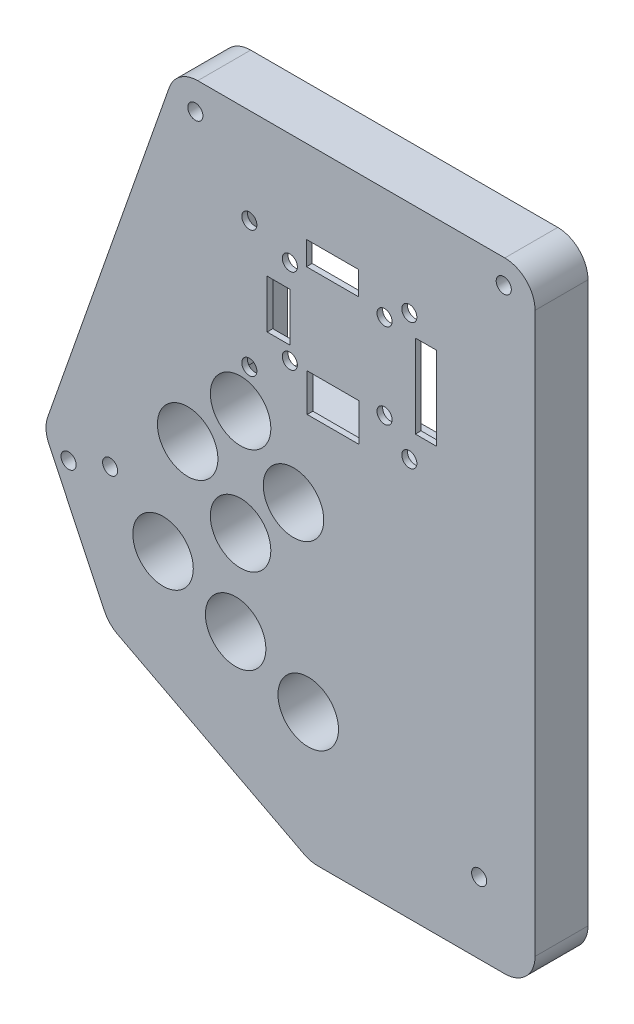
from build123d import *

# Parameters (mm, degrees)
BOSS_EXTRUDE1_DEPTH      = 8.89
SKETCH9_R                = 1.267511842
SKETCH9_W                = 3.81
SKETCH9_H                = 8.128
SKETCH9_W_2              = 3.556
SKETCH9_H_2              = 13.97
SKETCH9_W_3              = 8.73125
SKETCH9_H_3              = 3.96875
CUT_EXTRUDE6_DEPTH       = 1
CUT_EXTRUDE6_DEPTH_BACK  = 9.89
SKETCH4_W                = 34.29
SKETCH4_H                = 30.48
CUT_EXTRUDE7_DEPTH       = 7.9375
CUT_EXTRUDE7_DEPTH_BACK  = 1
SKETCH3_R                = 5.08
CUT_EXTRUDE8_DEPTH       = 1
CUT_EXTRUDE8_DEPTH_BACK  = 9.89
SKETCH12_R               = 1.27
CUT_EXTRUDE9_DEPTH       = 1
CUT_EXTRUDE9_DEPTH_BACK  = 9.89
SKETCH15_R               = 1.27
CUT_EXTRUDE10_DEPTH      = 1
CUT_EXTRUDE10_DEPTH_BACK = 9.89


with BuildPart() as part:
    # Sketch1 → Boss-Extrude1 (new body)
    with BuildSketch(Plane.XY):
        with BuildLine():
            Line((-3.314058103, 6.35), (48.26, 6.35))
            ThreePointArc((48.26, 6.35), (51.852102448, 4.862102448), (53.34, 1.27))
            Line((53.34, 1.27), (53.34, -92.71))
            ThreePointArc((53.34, -92.71), (51.852102448, -96.302102448), (48.26, -97.79))
            Line((48.26, -97.79), (16.846989059, -97.79))
            ThreePointArc((16.846989059, -97.79), (15.638688158, -97.644208035), (14.499741809, -97.215200367))
            Line((14.499741809, -97.215200367), (-16.7505185, -80.933552139))
            ThreePointArc((-16.7505185, -80.933552139), (-18.059258376, -79.955412607), (-18.989802686, -78.61241436))
            Line((-18.989802686, -78.61241436), (-28.309569459, -59.040904135))
            ThreePointArc((-28.309569459, -59.040904135), (-28.795802898, -57.127870198), (-28.51617555, -55.173917704))
            Line((-28.51617555, -55.173917704), (-8.107195629, 2.952923842))
            ThreePointArc((-8.107195629, 2.952923842), (-6.251501454, 5.414614163), (-3.314058103, 6.35))
        make_face()
    extrude(amount=BOSS_EXTRUDE1_DEPTH)

    # Sketch9 → Cut-Extrude6 (cut, two sides)
    with BuildSketch(Plane(origin=(0, 0, 0), x_dir=(-1, 0, 0), z_dir=(0, 0, -1))) as cut_extrude6_sk:
        with Locations((-5.348417946, -30.953529248)):
            Circle(SKETCH9_R)
        with Locations((-32.218986844, -9.676052932)):
            Circle(SKETCH9_R)
        with Locations((-12.150498686, -12.37729109)):
            Circle(SKETCH9_R)
        with Locations((-12.150498686, -26.66479109)):
            Circle(SKETCH9_R)
        with Locations((-28.057248686, -12.37729109)):
            Circle(SKETCH9_R)
        with Locations((-5.348417946, -9.676052932)):
            Circle(SKETCH9_R)
        with Locations((-32.218986844, -30.953529248)):
            Circle(SKETCH9_R)
        with Locations((-28.057248686, -26.66479109)):
            Circle(SKETCH9_R)
        with Locations((-10.245904396, -20.31479109)):
            Rectangle(SKETCH9_W, SKETCH9_H)
        Polygon((-15.064842187, -33.01479109), (-23.802748686, -33.01479109), (-23.802748686, -26.66479109), (-20.913498686, -26.66479109), (-15.064842187, -26.66479109), align=None)
        with Locations((-35.010498686, -19.798068783)):
            Rectangle(SKETCH9_W_2, SKETCH9_H_2)
        with Locations((-19.310123686, -9.59916609)):
            Rectangle(SKETCH9_W_3, SKETCH9_H_3)
    extrude(amount=CUT_EXTRUDE6_DEPTH, mode=Mode.SUBTRACT)
    extrude(cut_extrude6_sk.sketch, amount=-CUT_EXTRUDE6_DEPTH_BACK, mode=Mode.SUBTRACT)

    # Sketch4 → Cut-Extrude7 (cut, two sides)
    with BuildSketch(Plane.XY) as cut_extrude7_sk:
        with Locations((20.024498686, -18.415)):
            Rectangle(SKETCH4_W, SKETCH4_H)
    extrude(amount=CUT_EXTRUDE7_DEPTH, mode=Mode.SUBTRACT)
    extrude(cut_extrude7_sk.sketch, amount=-CUT_EXTRUDE7_DEPTH_BACK, mode=Mode.SUBTRACT)

    # Sketch3 → Cut-Extrude8 (cut, two sides)
    with BuildSketch(Plane.XY.offset(8.89)) as cut_extrude8_sk:
        with Locations((3.878385852, -38.1)):
            Circle(SKETCH3_R)
        with Locations((-5.011614148, -46.99)):
            Circle(SKETCH3_R)
        with Locations((3.878385852, -55.88)):
            Circle(SKETCH3_R)
        with Locations((12.768385852, -46.99)):
            Circle(SKETCH3_R)
        with Locations((-9.144, -65.024)):
            Circle(SKETCH3_R)
        with Locations((3.048, -70.612)):
            Circle(SKETCH3_R)
        with Locations((15.24, -76.2)):
            Circle(SKETCH3_R)
    extrude(amount=CUT_EXTRUDE8_DEPTH, mode=Mode.SUBTRACT)
    extrude(cut_extrude8_sk.sketch, amount=-CUT_EXTRUDE8_DEPTH_BACK, mode=Mode.SUBTRACT)

    # Sketch12 → Cut-Extrude9 (cut, two sides)
    with BuildSketch(Plane(origin=(0, 0, 0), x_dir=(-1, 0, 0), z_dir=(0, 0, -1))) as cut_extrude9_sk:
        with Locations((-48.0822, 2.286)):
            Circle(SKETCH12_R)
        with Locations((3.718687848, 1.651)):
            Circle(SKETCH12_R)
        with Locations((25.012261453, -59.761967182)):
            Circle(SKETCH12_R)
    extrude(amount=CUT_EXTRUDE9_DEPTH, mode=Mode.SUBTRACT)
    extrude(cut_extrude9_sk.sketch, amount=-CUT_EXTRUDE9_DEPTH_BACK, mode=Mode.SUBTRACT)

    # Sketch15 → Cut-Extrude10 (cut, two sides)
    with BuildSketch(Plane(origin=(0, 0, 0), x_dir=(-1, 0, 0), z_dir=(0, 0, -1))) as cut_extrude10_sk:
        with Locations((18.034, -57.15)):
            Circle(SKETCH15_R)
        with Locations((-43.942, -85.852)):
            Circle(SKETCH15_R)
    extrude(amount=CUT_EXTRUDE10_DEPTH, mode=Mode.SUBTRACT)
    extrude(cut_extrude10_sk.sketch, amount=-CUT_EXTRUDE10_DEPTH_BACK, mode=Mode.SUBTRACT)


solid = part.part
